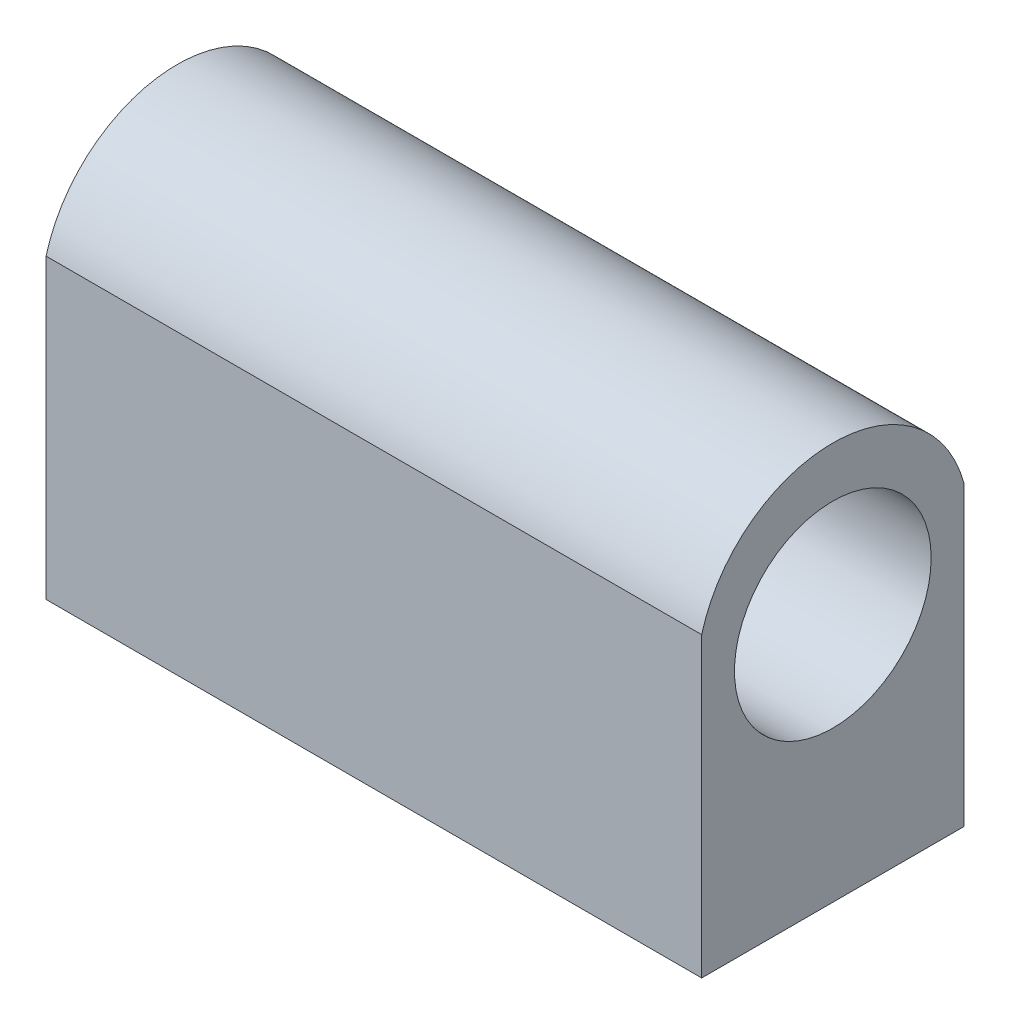
from build123d import *

# Parameters (mm, degrees)
SKETCH1_W               = 50
SKETCH1_H               = 20
BOSS_EXTRUDE1_DEPTH     = 44
SKETCH3_R               = 7.5
CUT_EXTRUDE3_DEPTH      = 26
CUT_EXTRUDE3_DEPTH_BACK = 26
CUT_EXTRUDE4_DEPTH      = 26
CUT_EXTRUDE4_DEPTH_BACK = 26


with BuildPart() as part:
    # Sketch1 → Boss-Extrude1 (new body)
    with BuildSketch(Plane(origin=(0, 0, 0), x_dir=(1, 0, 0), z_dir=(0, 1, 0))):
        Rectangle(SKETCH1_W, SKETCH1_H)
    extrude(amount=BOSS_EXTRUDE1_DEPTH)

    # Sketch3 → Cut-Extrude3 (cut, two sides)
    with BuildSketch(Plane(origin=(0, 0, 0), x_dir=(0, 0, -1), z_dir=(1, 0, 0))) as cut_extrude3_sk:
        with Locations((0, 19)):
            Circle(SKETCH3_R)
    extrude(amount=CUT_EXTRUDE3_DEPTH, mode=Mode.SUBTRACT)
    extrude(cut_extrude3_sk.sketch, amount=-CUT_EXTRUDE3_DEPTH_BACK, mode=Mode.SUBTRACT)

    # Sketch4 → Cut-Extrude4 (cut, two sides)
    with BuildSketch(Plane(origin=(0, 0, 0), x_dir=(0, 0, -1), z_dir=(1, 0, 0))) as cut_extrude4_sk:
        with BuildLine():
            Line((-10, 22.677289201), (-10, 44))
            Line((-10, 44), (10, 44))
            Line((10, 44), (10, 22.677289201))
            ThreePointArc((10, 22.677289201), (0, 30.338307173), (-10, 22.677289201))
        make_face()
    extrude(amount=CUT_EXTRUDE4_DEPTH, mode=Mode.SUBTRACT)
    extrude(cut_extrude4_sk.sketch, amount=-CUT_EXTRUDE4_DEPTH_BACK, mode=Mode.SUBTRACT)


solid = part.part
